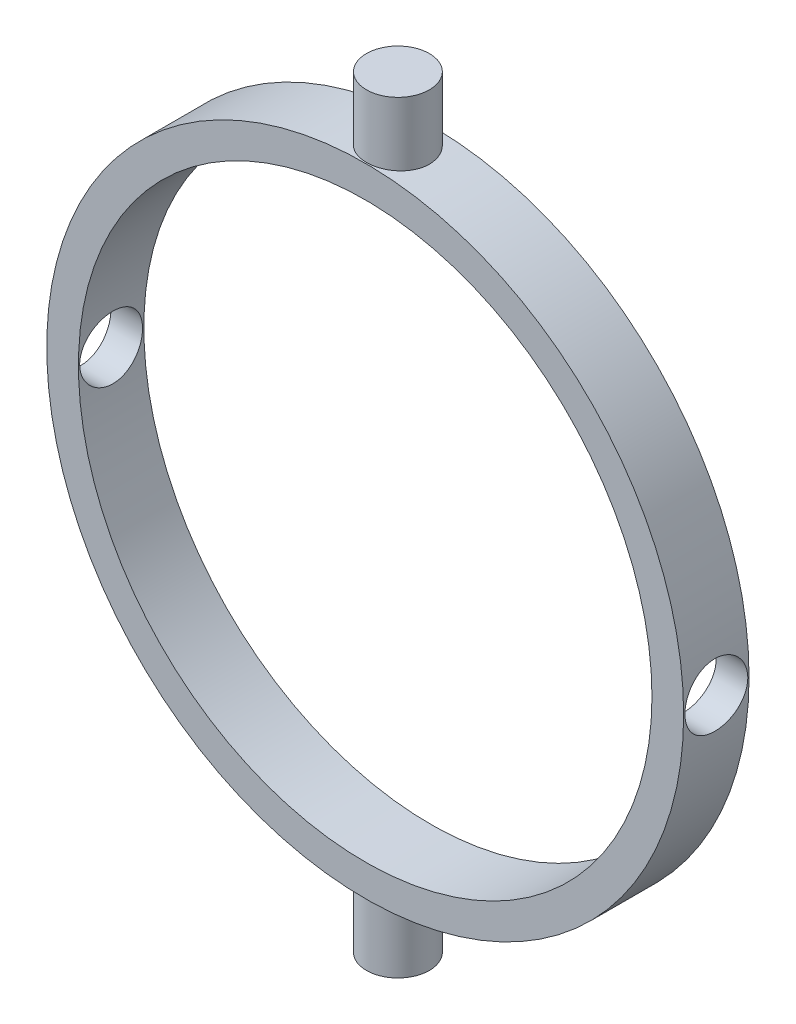
from build123d import *

# Parameters (mm, degrees)
SKETCH1_R           = 16.078
SKETCH1_R_2         = 14.478
BOSS_EXTRUDE1_DEPTH = 3.302
SKETCH2_R           = 1.5875
CUT_EXTRUDE1_DEPTH  = 33.156
BOSS_EXTRUDE2_START = -0.635
SKETCH3_R           = 1.5875
BOSS_EXTRUDE2_DEPTH = 3.81
CIRPATTERN1_COUNT   = 2


with BuildPart() as part:
    # Sketch1 → Boss-Extrude1 (new body)
    with BuildSketch(Plane.XY):
        Circle(SKETCH1_R)
        Circle(SKETCH1_R_2, mode=Mode.SUBTRACT)
    extrude(amount=BOSS_EXTRUDE1_DEPTH)

    # Sketch2 → Cut-Extrude1 (cut, through all)
    with BuildSketch(Plane(origin=(16.078, 0, 0), x_dir=(0, 0, -1), z_dir=(1, 0, 0))):
        with Locations((-1.651, 0)):
            Circle(SKETCH2_R)
    extrude(amount=-CUT_EXTRUDE1_DEPTH, mode=Mode.SUBTRACT)

    # Sketch3 → Boss-Extrude2 (add)
    with BuildSketch(Plane(origin=(0, 16.078, 0), x_dir=(-1, 0, 0), z_dir=(0, 1, 0)).offset(BOSS_EXTRUDE2_START)):
        with Locations(Location((0, 1.651, 0), (0, 0, 90))):  # turned: the seam where the file's is
            Circle(SKETCH3_R)
    boss_extrude2 = extrude(amount=BOSS_EXTRUDE2_DEPTH)

    # CirPattern1: Boss-Extrude2 ×2 about axis
    cirpattern1_axis = Axis((0, 0, 3.302), (0, 0, -1))
    for i in range(1, CIRPATTERN1_COUNT):
        add(boss_extrude2.rotate(cirpattern1_axis, i * 360 / CIRPATTERN1_COUNT))


solid = part.part
